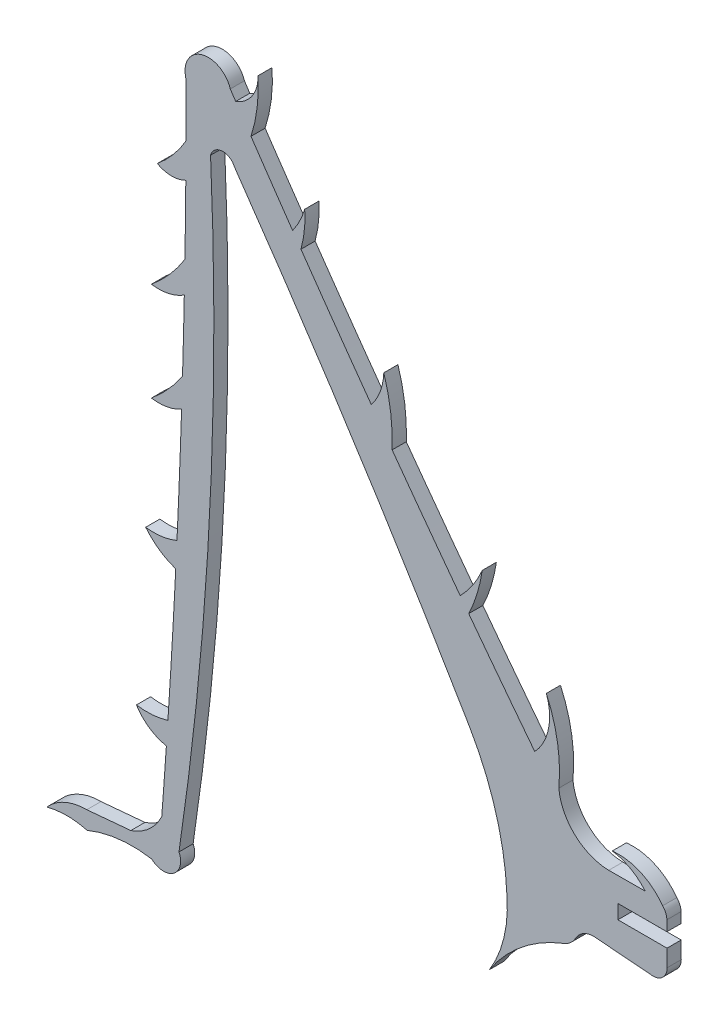
from build123d import *

# Parameters (mm, degrees)
BOSS_EXTRUDE1_DEPTH = 1.524


with BuildPart() as part:
    # Sketch1 → Boss-Extrude1 (new body)
    with BuildSketch(Plane.XY):
        with BuildLine():
            Line((-24.364554891, -37.477178577), (-29.107446573, -37.903411516))
            ThreePointArc((-29.107446573, -37.903411516), (-31.473071099, -38.393425652), (-33.42606857, -39.815429216))
            ThreePointArc((-33.42606857, -39.815429216), (-31.249893388, -39.522353453), (-29.073637755, -39.814831212))
            ThreePointArc((-29.073637755, -39.814831212), (-25.648712592, -38.918813581), (-22.109711099, -39.010619897))
            ThreePointArc((-22.109711099, -39.010619897), (-19.760509062, -39.158760526), (-19.17540942, -36.878770555))
            ThreePointArc((-19.17540942, -36.878770555), (-15.865162798, -3.599783912), (-15.772880419, 29.843304591))
            ThreePointArc((-15.772880419, 29.843304591), (-14.548235849, 30.854621423), (-13.192137962, 30.027872017))
            ThreePointArc((-13.192137962, 30.027872017), (-0.136306851, 10.515149008), (12.117439823, -9.511003335))
            ThreePointArc((12.117439823, -9.511003335), (14.987237528, -16.164940717), (16.168465676, -23.314438715))
            ThreePointArc((16.168465676, -23.314438715), (15.842573186, -27.376128515), (14.280506414, -31.139568078))
            ThreePointArc((14.280506414, -31.139568078), (17.769072475, -27.290062934), (22.267530319, -24.691474848))
            ThreePointArc((22.267530319, -24.691474848), (23.021800675, -24.236514222), (23.57532619, -23.551297143))
            ThreePointArc((23.57532619, -23.551297143), (24.39123878, -22.713681417), (25.519929239, -22.408114227))
            Line((25.519929239, -22.408114227), (31.91215665, -22.925682288))
            ThreePointArc((31.91215665, -22.925682288), (32.987506925, -22.470894628), (33.426022068, -21.3888066))
            Line((33.426022068, -21.3888066), (33.414100594, -19.560808287))
            Line((33.414100594, -19.560808287), (28.122840134, -19.561801701))
            Line((28.122840134, -19.561801701), (28.110918151, -18.035820501))
            Line((28.110918151, -18.035820501), (33.406152775, -18.035820501))
            Line((33.406152775, -18.035820501), (33.398174437, -16.925455032))
            ThreePointArc((33.398174437, -16.925455032), (33.278622124, -16.341687991), (32.944745486, -15.848126338))
            ThreePointArc((32.944745486, -15.848126338), (30.558622948, -13.902263693), (27.514270045, -13.441962054))
            ThreePointArc((27.514270045, -13.441962054), (29.473047609, -14.099689708), (31.069176316, -15.411859044))
            Line((31.069176316, -15.411859044), (27.131733148, -15.435585668))
            ThreePointArc((27.131733148, -15.435585668), (23.499650774, -13.970182339), (21.752807973, -10.464762321))
            ThreePointArc((21.752807973, -10.464762321), (21.619864509, -6.287804949), (20.411069114, -2.287372404))
            ThreePointArc((20.411069114, -2.287372404), (20.646164492, -5.489635666), (19.164832874, -8.338392672))
            ThreePointArc((19.164832874, -8.338392672), (15.589025091, -3.695796166), (12.046655257, 0.972364027))
            ThreePointArc((12.046655257, 0.972364027), (12.956062916, 3.299009299), (13.502748407, 5.736515296))
            ThreePointArc((13.502748407, 5.736515296), (12.481630447, 3.853470902), (11.130205062, 2.191487897))
            ThreePointArc((11.130205062, 2.191487897), (7.442893614, 7.145097778), (3.793181539, 12.12647493))
            ThreePointArc((3.793181539, 12.12647493), (3.6391771, 15.54128121), (2.898904085, 18.878437958))
            ThreePointArc((2.898904085, 18.878437958), (2.513226677, 16.946929667), (1.548714149, 15.229609975))
            ThreePointArc((1.548714149, 15.229609975), (-2.262432259, 20.570077326), (-6.030509674, 25.941019614))
            ThreePointArc((-6.030509674, 25.941019614), (-5.660787122, 27.892481118), (-5.62524637, 29.878339526))
            ThreePointArc((-5.62524637, 29.878339526), (-6.161870131, 28.501450031), (-6.932604962, 27.240594145))
            ThreePointArc((-6.932604962, 27.240594145), (-9.183193775, 30.506482698), (-11.417879239, 33.783273646))
            ThreePointArc((-11.417879239, 33.783273646), (-10.755972391, 36.763721595), (-10.665026003, 39.815429216))
            ThreePointArc((-10.665026003, 39.815429216), (-11.282248363, 37.628788529), (-13.063123372, 36.21781541))
            ThreePointArc((-13.063123372, 36.21781541), (-13.355981093, 36.653158865), (-13.648558784, 37.088690566))
            ThreePointArc((-13.648558784, 37.088690566), (-16.663200217, 38.770611805), (-18.464850886, 35.825959552))
            ThreePointArc((-18.464850886, 35.825959552), (-18.420691896, 35.556546257), (-18.405703646, 35.283949682))
            ThreePointArc((-18.405703646, 35.283949682), (-18.40664027, 32.572114189), (-18.415743017, 29.860293811))
            ThreePointArc((-18.415743017, 29.860293811), (-19.802823987, 27.891016102), (-21.515118511, 26.1968804))
            ThreePointArc((-21.515118511, 26.1968804), (-19.981611623, 25.800865516), (-18.441254033, 26.16933486))
            ThreePointArc((-18.441254033, 26.16933486), (-18.482213638, 22.453964053), (-18.538502103, 18.738793864))
            ThreePointArc((-18.538502103, 18.738793864), (-20.176761137, 16.529345851), (-22.151609818, 14.614789539))
            ThreePointArc((-22.151609818, 14.614789539), (-20.30809135, 14.67247237), (-18.602694106, 15.374973539))
            ThreePointArc((-18.602694106, 15.374973539), (-18.691127928, 11.543467884), (-18.795866803, 7.712373276))
            ThreePointArc((-18.795866803, 7.712373276), (-20.334999659, 5.725783654), (-22.151609818, 3.989294148))
            ThreePointArc((-22.151609818, 3.989294148), (-20.47435397, 4.014209715), (-18.893763009, 4.575939347))
            ThreePointArc((-18.893763009, 4.575939347), (-19.121395234, -1.672175675), (-19.392400358, -7.918559748))
            ThreePointArc((-19.392400358, -7.918559748), (-21.046264617, -8.374679978), (-22.761865121, -8.369430126))
            ThreePointArc((-22.761865121, -8.369430126), (-21.306272714, -9.735931232), (-19.523833936, -10.635368018))
            ThreePointArc((-19.523833936, -10.635368018), (-19.916786026, -17.918683373), (-20.36871487, -25.198577206))
            ThreePointArc((-20.36871487, -25.198577206), (-22.05068144, -25.516497621), (-23.761121477, -25.44956621))
            ThreePointArc((-23.761121477, -25.44956621), (-22.378228066, -26.891420245), (-20.535063915, -27.662188146))
            ThreePointArc((-20.535063915, -27.662188146), (-20.777686634, -31.088285528), (-21.033374555, -34.513432641))
            ThreePointArc((-21.033374555, -34.513432641), (-22.397678986, -36.333943653), (-24.364554891, -37.477178577))
        make_face()
    extrude(amount=BOSS_EXTRUDE1_DEPTH)


solid = part.part
